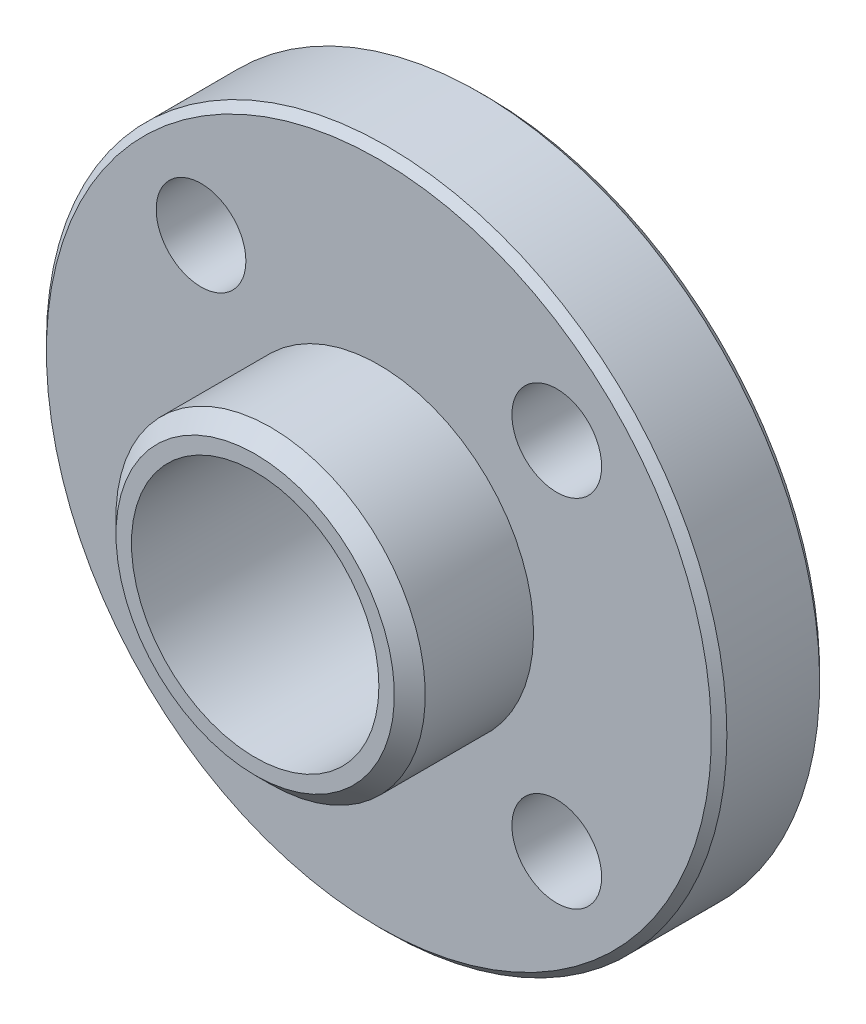
from build123d import *

# Parameters (mm, degrees)
SKETCH2_R               = 4
CUT_EXTRUDE1_DEPTH      = 12.5
CHAMFER1_SIZE           = 0.5
CHAMFER2_SIZE           = 0.25
M3_5X0_6_TAPPED_HOLE1_D = 2.9


with BuildPart() as part:
    # Sketch1 → Revolve1 (revolve)
    with BuildSketch(Plane(origin=(0, 0, 0), x_dir=(0, 0, -1), z_dir=(1, 0, 0))):
        Polygon((-5.75, 0), (-5.75, 5), (-1.75, 5), (-1.75, 11), (1.75, 11), (1.75, 5), (5.75, 5), (5.75, 0), align=None)
    revolve(axis=Axis((0, 0, 5.75), (0, 0, -1)))

    # Sketch2 → Cut-Extrude1 (cut, through all)
    with BuildSketch(Plane.XY.offset(5.75)):
        Circle(SKETCH2_R)
    extrude(amount=-CUT_EXTRUDE1_DEPTH, mode=Mode.SUBTRACT)

    # Chamfer1
    chamfer1_edges = [part.edges().sort_by_distance(p)[0] for p in [
        (0, -5, -5.75),
        (0, -5, 5.75),
    ]]
    chamfer(chamfer1_edges, length=CHAMFER1_SIZE)

    # Chamfer2
    chamfer2_edges = [part.edges().sort_by_distance(p)[0] for p in [
        (0, -11, -1.75),
        (0, -11, 1.75),
    ]]
    chamfer(chamfer2_edges, length=CHAMFER2_SIZE)

    # M3.5x0.6 Tapped Hole1 (through all)
    with Locations(Plane.XY.offset(1.75)):
        with Locations((-5.75, 5.75), (5.75, 5.75), (5.75, -5.75), (-5.75, -5.75)):
            Hole(M3_5X0_6_TAPPED_HOLE1_D / 2)


solid = part.part
